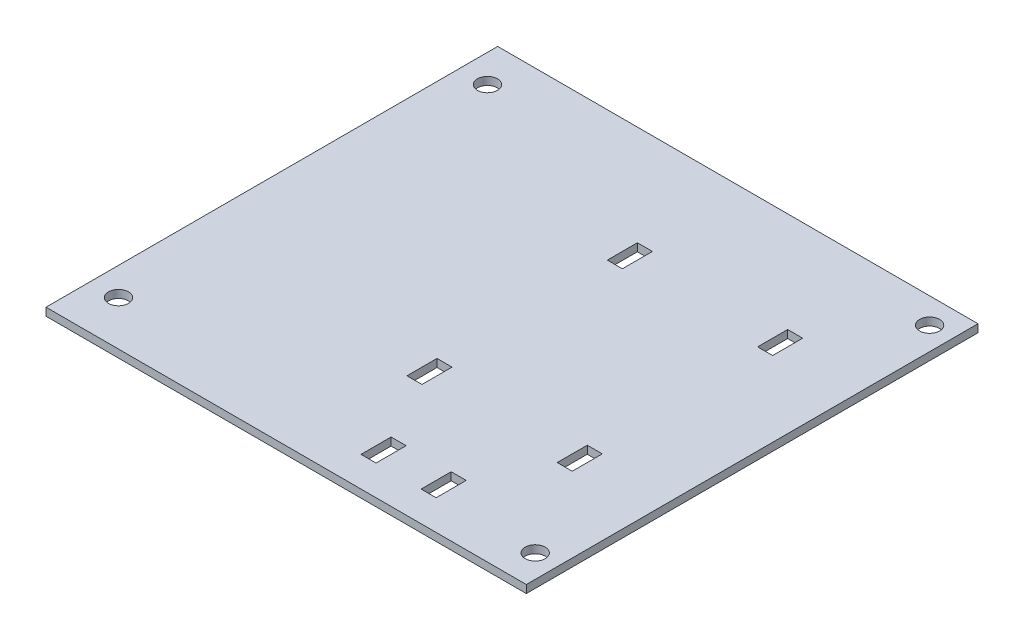
from build123d import *

# Parameters (mm, degrees)
SKETCH1_W               = 96.89
SKETCH1_H               = 90.17
PCB_DEPTH               = 1.57
SKETCH2_R               = 2
M3_MOUNTING_HOLES_DEPTH = 1.57
SKETCH5_W               = 0.5
SKETCH5_H               = 90.17
CUT_EXTRUDE1_DEPTH      = 2.57
SKETCH6_W               = 3
SKETCH6_H               = 6
ZIPTIE_HOLDS_DEPTH      = 10


with BuildPart() as part:
    # Sketch1 → PCB (new body)
    with BuildSketch(Plane(origin=(0, 0, 0), x_dir=(1, 0, 0), z_dir=(0, 1, 0))):
        with Locations((16.200949951, 63.633996534)):
            Rectangle(SKETCH1_W, SKETCH1_H)
    extrude(amount=PCB_DEPTH)

    # Sketch2 → M3 Mounting Holes (cut)
    with BuildSketch(Plane(origin=(0, 1.57, 0), x_dir=(1, 0, 0), z_dir=(0, 1, 0))):
        with Locations((59.565949951, 24.898996534)):
            Circle(SKETCH2_R)
        with Locations((-26.164050049, 27.438996534)):
            Circle(SKETCH2_R)
        with Locations((-26.164050049, 101.098996534)):
            Circle(SKETCH2_R)
        with Locations((59.565949951, 103.638996534)):
            Circle(SKETCH2_R)
    extrude(amount=-M3_MOUNTING_HOLES_DEPTH, mode=Mode.SUBTRACT)

    # Sketch5 → Cut-Extrude1 (cut, through all)
    with BuildSketch(Plane(origin=(0, 1.57, 0), x_dir=(1, 0, 0), z_dir=(0, 1, 0))):
        with Locations((-31.994050049, 63.633996534)):
            Rectangle(SKETCH5_W, SKETCH5_H)
        with Locations((64.395949951, 63.633996534)):
            Rectangle(SKETCH5_W, SKETCH5_H)
    extrude(amount=-CUT_EXTRUDE1_DEPTH, mode=Mode.SUBTRACT)

    # Sketch6 → ZipTie Holds (cut)
    with BuildSketch(Plane(origin=(0, 1.57, 0), x_dir=(1, 0, 0), z_dir=(0, 1, 0))):
        with Locations((17.645949951, 85.718996534)):
            Rectangle(SKETCH6_W, SKETCH6_H)
        with Locations((47.645949951, 85.718996534)):
            Rectangle(SKETCH6_W, SKETCH6_H)
        with Locations((17.645949951, 45.718996534)):
            Rectangle(SKETCH6_W, SKETCH6_H)
        with Locations((47.645949951, 45.718996534)):
            Rectangle(SKETCH6_W, SKETCH6_H)
        with Locations((26.645949951, 27.548996534)):
            Rectangle(SKETCH6_W, SKETCH6_H)
        with Locations((38.645949951, 27.548996534)):
            Rectangle(SKETCH6_W, SKETCH6_H)
    extrude(amount=-ZIPTIE_HOLDS_DEPTH, mode=Mode.SUBTRACT)


solid = part.part
